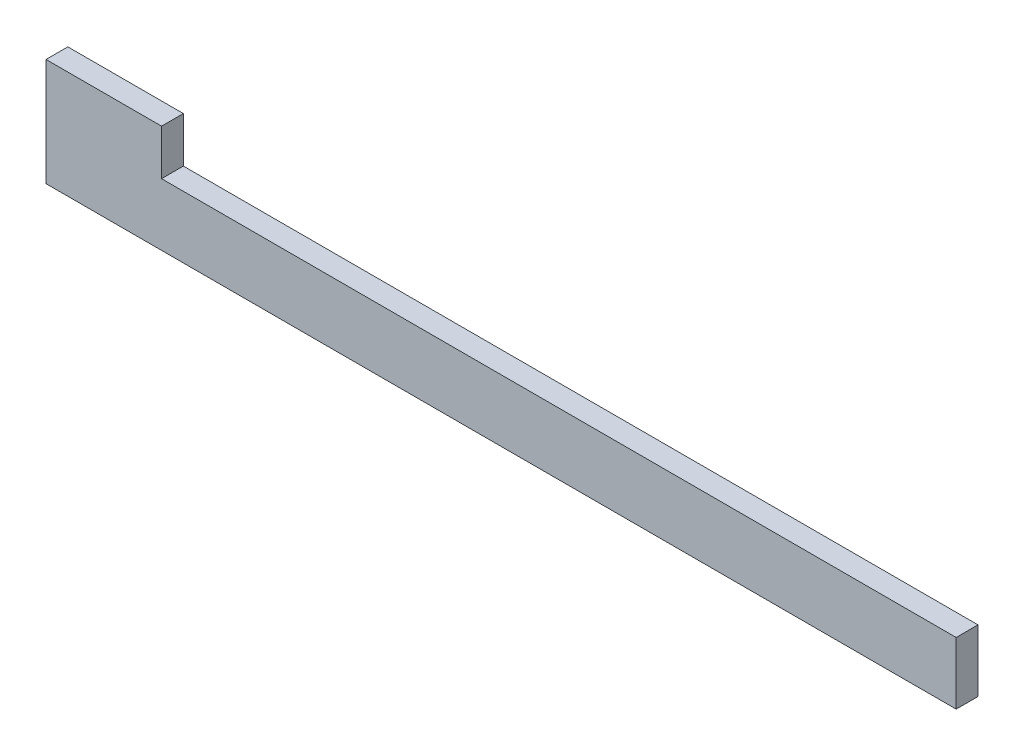
from build123d import *

# Parameters (mm, degrees)
EXTRUDE_1_DEPTH = 10


with BuildPart() as part:
    # 草图1 → 凸台-拉伸1 (new body)
    with BuildSketch(Plane.XY):
        Polygon((-82.531326421, -18.440504625), (-82.531326421, 10), (-82.531326421, 30.835132221), (-29.614564371, 30.835132221), (-29.614564371, 10), (334.308144959, 10), (334.308144959, -18.440504625), align=None)
    extrude(amount=EXTRUDE_1_DEPTH)


solid = part.part
